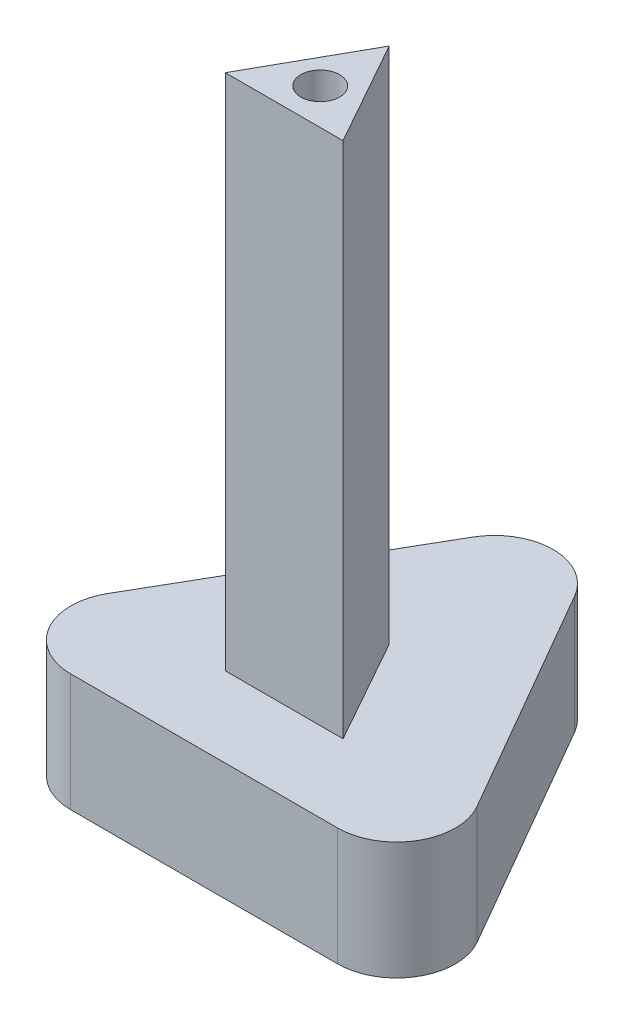
from build123d import *

# Parameters (mm, degrees)
EXTRUDE_1_DEPTH        = 10
FILLET_1_R             = 5
EXTRUDE_2_DEPTH        = 44
HOLE_WIZARD_M4_1_D     = 3.3
HOLE_WIZARD_M4_1_DEPTH = 10.1
HOLE_WIZARD_M4_1_TIP   = 0.991420021


with BuildPart() as part:
    # 草图1 → 凸台-拉伸1 (new body)
    with BuildSketch(Plane(origin=(0, 0, 0), x_dir=(1, 0, 0), z_dir=(0, 1, 0))):
        Polygon((-17.113074928, 2.840600346), (-37.113074928, -31.800415806), (2.886925072, -31.800415806), align=None)
    extrude(amount=EXTRUDE_1_DEPTH)

    # 圆角1
    fillet_1_edges = [part.edges().sort_by_distance(p)[0] for p in [
        (2.886925072, 5, 31.800415806),
        (-37.113074928, 5, 31.800415806),
        (-17.113074928, 5, -2.840600346),
    ]]
    fillet(fillet_1_edges, radius=FILLET_1_R)

    # 草图2 → 凸台-拉伸2 (add)
    with BuildSketch(Plane(origin=(0, 10, 0), x_dir=(1, 0, 0), z_dir=(0, 1, 0))):
        Polygon((-17.113074928, -16.086161566), (-12.113074928, -25.011274713), (-22.113074928, -25.011274713), align=None)
    extrude(amount=EXTRUDE_2_DEPTH)

    # M4 螺纹孔1
    with Locations(Plane(origin=(0, 54, 0), x_dir=(1, 0, 0), z_dir=(0, 1, 0))):
        with Locations((-17.113074928, -21.949260608)):
            Hole(HOLE_WIZARD_M4_1_D / 2, depth=HOLE_WIZARD_M4_1_DEPTH)
            with Locations((0, 0, -(HOLE_WIZARD_M4_1_DEPTH + HOLE_WIZARD_M4_1_TIP / 2))):  # 118° drill point
                Cone(0, HOLE_WIZARD_M4_1_D / 2, HOLE_WIZARD_M4_1_TIP, mode=Mode.SUBTRACT)


solid = part.part
